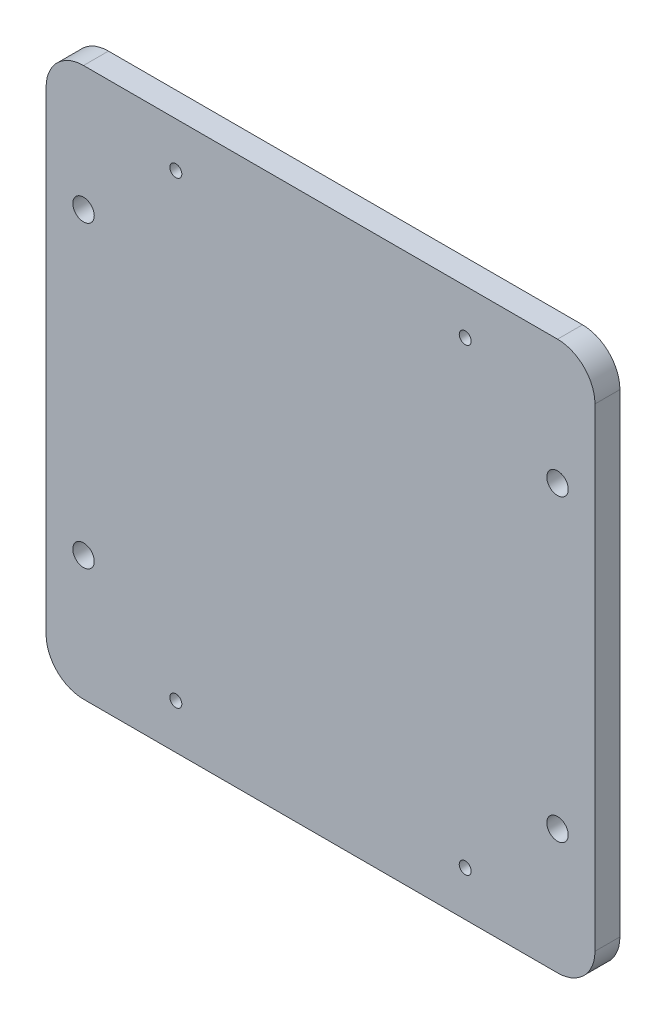
from build123d import *

# Parameters (mm, degrees)
SKETCH_1_W         = 110
SKETCH_1_H         = 110
EXTRUDE_1_DEPTH    = 5
HOLE_WIZARD_M2_1_D = 2.4
HOLE_WIZARD_M4_1_D = 4.3
FILLET_1_R         = 7.5


with BuildPart() as part:
    # ｽｹｯﾁ1 → ﾎﾞｽ - 押し出し1 (new body)
    with BuildSketch(Plane(origin=(0, 0, 0), x_dir=(0, 1, 0), z_dir=(0, 0, 1))):
        with Locations((55, 55)):
            Rectangle(SKETCH_1_W, SKETCH_1_H)
    extrude(amount=EXTRUDE_1_DEPTH)

    # M2 すきま穴1 (through all)
    with Locations(Plane.XY.offset(5)):
        with Locations((-84, 9), (-84, 101), (-26, 101), (-26, 9)):
            Hole(HOLE_WIZARD_M2_1_D / 2)

    # M4 すきま穴1 (through all)
    with Locations(Plane.XY.offset(5)):
        with Locations((-102.5, 85), (-102.5, 25), (-7.5, 25), (-7.5, 85)):
            Hole(HOLE_WIZARD_M4_1_D / 2)

    # ﾌｨﾚｯﾄ1
    fillet_1_edges = [part.edges().sort_by_distance(p)[0] for p in [
        (-110, 0, 2.5),
        (-110, 110, 2.5),
        (0, 110, 2.5),
        (0, 0, 2.5),
    ]]
    fillet(fillet_1_edges, radius=FILLET_1_R)


solid = part.part
